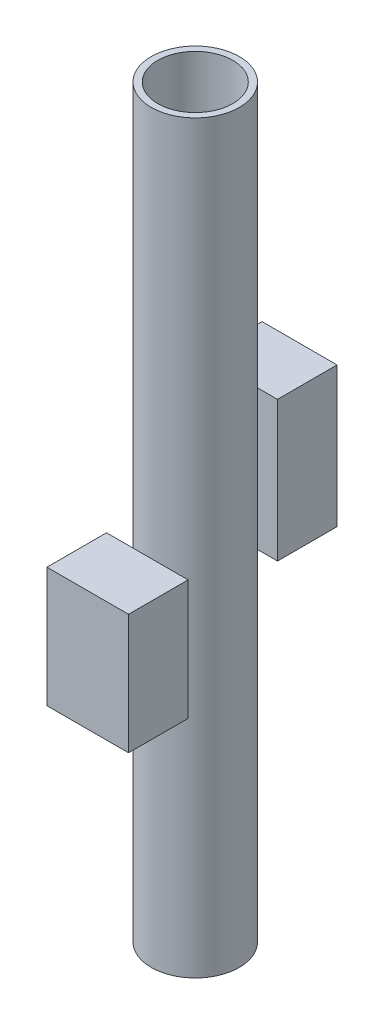
from build123d import *

# Parameters (mm, degrees)
SKETCH1_R           = 14.78728341
BOSS_EXTRUDE1_DEPTH = 250
SKETCH2_R           = 12.59408245
CUT_EXTRUDE1_DEPTH  = 250
SKETCH4_R           = 12.59408245
BOSS_EXTRUDE2_DEPTH = 1.5
SKETCH5_R           = 12.59408245
BOSS_EXTRUDE3_DEPTH = 1.5
SKETCH7_W           = 27.38136586
SKETCH7_H           = 40.26816594
BOSS_EXTRUDE4_DEPTH = 20
SKETCH8_W           = 25.1881649
SKETCH8_H           = 47.017714204
BOSS_EXTRUDE5_DEPTH = 20


with BuildPart() as part:
    # Sketch1 → Boss-Extrude1 (new body)
    with BuildSketch(Plane(origin=(0, 0, 0), x_dir=(1, 0, 0), z_dir=(0, 1, 0))):
        Circle(SKETCH1_R)
    extrude(amount=BOSS_EXTRUDE1_DEPTH)

    # Sketch2 → Cut-Extrude1 (cut)
    with BuildSketch(Plane(origin=(0, 250, 0), x_dir=(1, 0, 0), z_dir=(0, 1, 0))):
        Circle(SKETCH2_R)
    extrude(amount=-CUT_EXTRUDE1_DEPTH, mode=Mode.SUBTRACT)

    # Sketch4 → Boss-Extrude2 (add, symmetric)
    with BuildSketch(Plane(origin=(0, 125, 0), x_dir=(1, 0, 0), z_dir=(0, 1, 0))):
        Circle(SKETCH4_R)
    extrude(amount=BOSS_EXTRUDE2_DEPTH, both=True)

    # Sketch5 → Boss-Extrude3 (add, symmetric)
    with BuildSketch(Plane(origin=(0, 100, 0), x_dir=(1, 0, 0), z_dir=(0, 1, 0))):
        Circle(SKETCH5_R)
    extrude(amount=BOSS_EXTRUDE3_DEPTH, both=True)


with BuildPart() as body_2:
    # Sketch7 → Boss-Extrude4 (new body)
    with BuildSketch(Plane.XY.offset(15)):
        with Locations((-1.09660048, 98.938392556)):
            Rectangle(SKETCH7_W, SKETCH7_H)
    extrude(amount=BOSS_EXTRUDE4_DEPTH)


with BuildPart() as body_3:
    # Sketch8 → Boss-Extrude5 (new body)
    with BuildSketch(Plane.XY.offset(-15)):
        with Locations((0, 133.039230776)):
            Rectangle(SKETCH8_W, SKETCH8_H)
    extrude(amount=-BOSS_EXTRUDE5_DEPTH)


solid = Compound([part.part, body_2.part, body_3.part])
